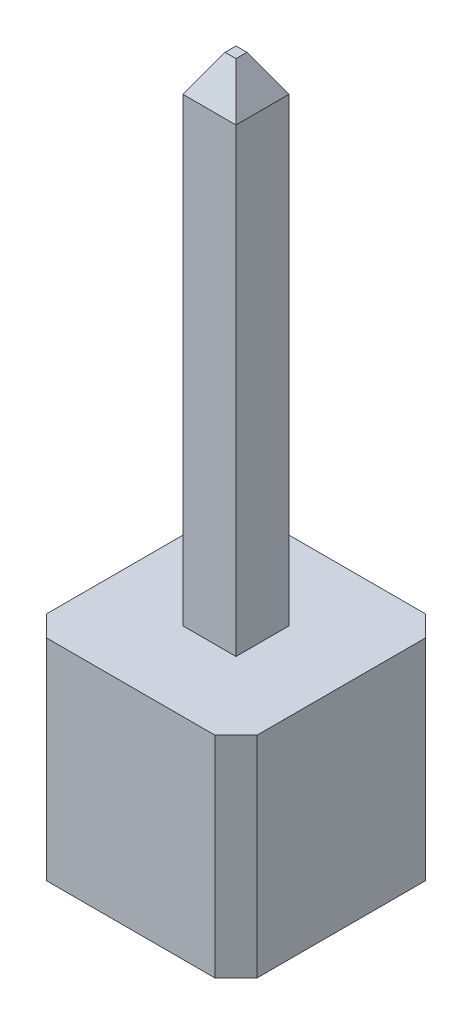
from build123d import *

# Parameters (mm, degrees)
SKETCH1_W           = 2.54
SKETCH1_H           = 2.54
SKETCH1_W_2         = 0.64
SKETCH1_H_2         = 0.64
BOSS_EXTRUDE1_DEPTH = 2.54
CHAMFER1_SIZE       = 0.254
SKETCH2_W           = 0.64
SKETCH2_H           = 0.64
BOSS_EXTRUDE2_DEPTH = 8.539999938
CHAMFER2_SIZE       = 0.254
CHAMFER2_SIZE2      = 0.439940905


with BuildPart() as part:
    # Sketch1 → Boss-Extrude1 (new body)
    with BuildSketch(Plane(origin=(0, 0, 0), x_dir=(1, 0, 0), z_dir=(0, 1, 0))):
        Rectangle(SKETCH1_W, SKETCH1_H)
        Rectangle(SKETCH1_W_2, SKETCH1_H_2, mode=Mode.SUBTRACT)
    extrude(amount=BOSS_EXTRUDE1_DEPTH)

    # Chamfer1
    chamfer1_edges = [part.edges().sort_by_distance(p)[0] for p in [
        (-1.27, 1.27, -1.27),
        (1.27, 1.27, -1.27),
        (1.27, 1.27, 1.27),
        (-1.27, 1.27, 1.27),
    ]]
    chamfer(chamfer1_edges, length=CHAMFER1_SIZE)


with BuildPart() as body_2:
    # Sketch2 → Boss-Extrude2 (new body)
    with BuildSketch(Plane.XZ):
        Rectangle(SKETCH2_W, SKETCH2_H)
    extrude(amount=-BOSS_EXTRUDE2_DEPTH)

    # Chamfer2
    chamfer2_edges = [body_2.edges().sort_by_distance(p)[0] for p in [
        (0.32, 8.539999938, 0),
        (0, 8.539999938, 0.32),
        (-0.32, 8.539999938, 0),
        (0, 8.539999938, -0.32),
    ]]
    chamfer2_side = [body_2.faces().sort_by_distance(p)[0] for p in [
        (0, 8.539999938, 0),
    ]]
    chamfer(chamfer2_edges, length=CHAMFER2_SIZE, length2=CHAMFER2_SIZE2, reference=chamfer2_side[0])


solid = Compound([part.part, body_2.part])
